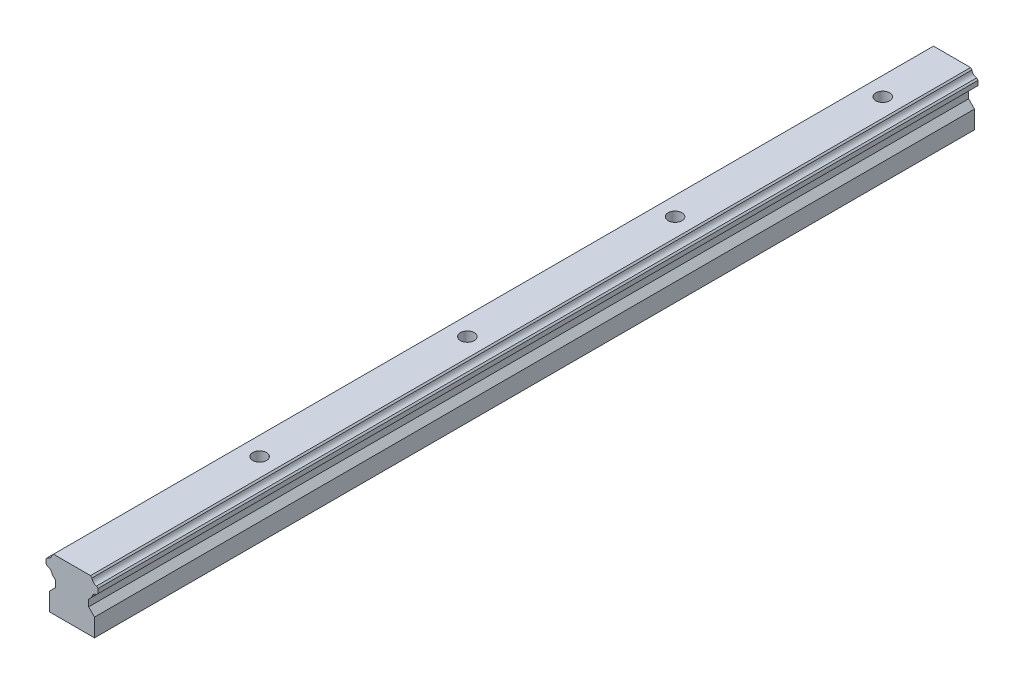
from build123d import *

# Parameters (mm, degrees)
BOSS_EXTRUDE1_DEPTH = 254
SKETCH2_R           = 2
CUT_EXTRUDE1_DEPTH  = 16


with BuildPart() as part:
    # Sketch1 → Boss-Extrude1 (new body)
    with BuildSketch(Plane.XY):
        with BuildLine():
            Line((-6.5, 0), (6.5, 0))
            Line((6.5, 0), (6.5, 5.2))
            Line((6.5, 5.2), (4.8, 6.9))
            Line((4.8, 6.9), (4.8, 8.84))
            Line((4.8, 8.84), (5.754868434, 9.794868434))
            ThreePointArc((5.754868434, 9.794868434), (6.196913421, 10.683086579), (7.085131566, 11.125131566))
            Line((7.085131566, 11.125131566), (7.5, 11.54))
            Line((7.5, 11.54), (7.5, 12.85))
            Line((7.5, 12.85), (7.08164233, 13.26835767))
            ThreePointArc((7.08164233, 13.26835767), (6.196913421, 13.709913421), (5.75535767, 14.59464233))
            Line((5.75535767, 14.59464233), (5.35, 15))
            Line((5.35, 15), (-5.35, 15))
            Line((-5.35, 15), (-5.75535767, 14.59464233))
            ThreePointArc((-5.75535767, 14.59464233), (-6.196913421, 13.709913421), (-7.08164233, 13.26835767))
            Line((-7.08164233, 13.26835767), (-7.5, 12.85))
            Line((-7.5, 12.85), (-7.5, 11.54))
            Line((-7.5, 11.54), (-7.085131566, 11.125131566))
            ThreePointArc((-7.085131566, 11.125131566), (-6.196913421, 10.683086579), (-5.754868434, 9.794868434))
            Line((-5.754868434, 9.794868434), (-4.8, 8.84))
            Line((-4.8, 8.84), (-4.8, 6.9))
            Line((-4.8, 6.9), (-6.5, 5.2))
            Line((-6.5, 5.2), (-6.5, 0))
        make_face()
    extrude(amount=BOSS_EXTRUDE1_DEPTH)

    # Sketch2 → Cut-Extrude1 (cut, through all)
    with BuildSketch(Plane(origin=(0, 15, 0), x_dir=(1, 0, 0), z_dir=(0, 1, 0))):
        with Locations((0, -20)):
            Circle(SKETCH2_R)
        with Locations((0, -79.944)):
            Circle(SKETCH2_R)
        with Locations((0, -139.888)):
            Circle(SKETCH2_R)
        with Locations((0, -199.832)):
            Circle(SKETCH2_R)
    extrude(amount=-CUT_EXTRUDE1_DEPTH, mode=Mode.SUBTRACT)


solid = part.part
